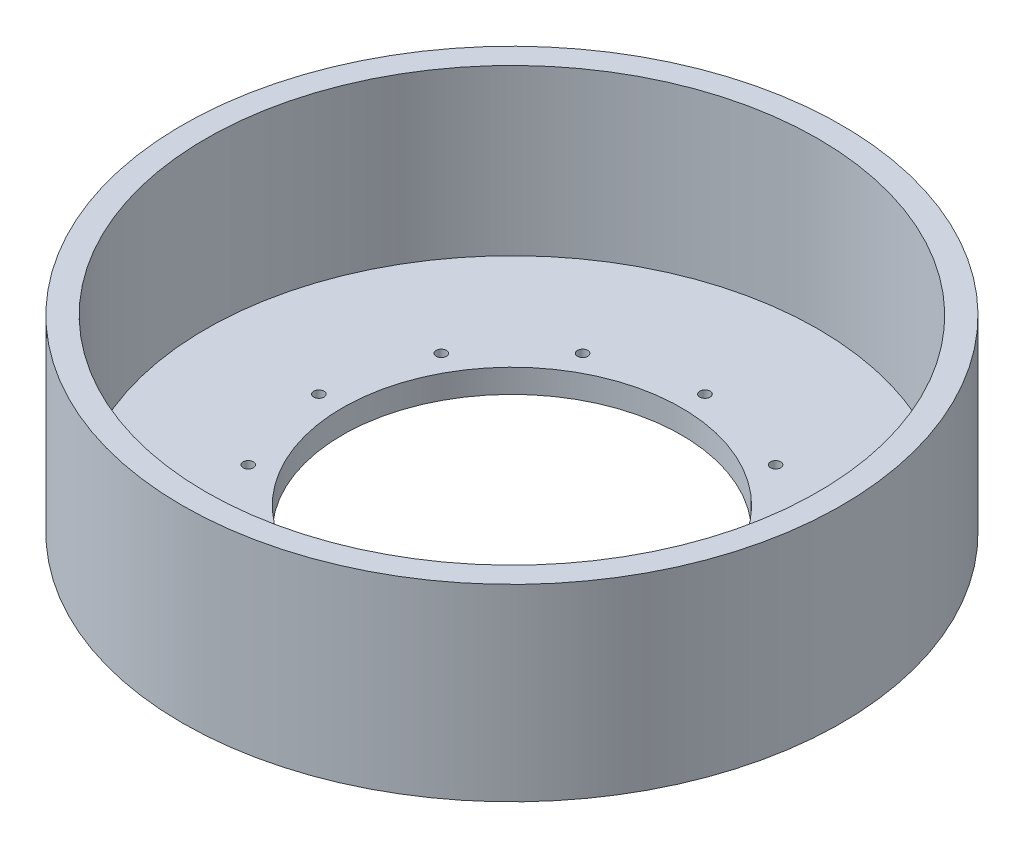
from build123d import *

# Parameters (mm, degrees)
SKETCH1_R           = 88.9
BOSS_EXTRUDE1_DEPTH = 50.8
SKETCH2_R           = 82.55
CUT_EXTRUDE1_DEPTH  = 44.45
SKETCH3_R           = 45.72
SKETCH3_R_2         = 1.397
CUT_EXTRUDE2_DEPTH  = 7.35


with BuildPart() as part:
    # Sketch1 → Boss-Extrude1 (new body)
    with BuildSketch(Plane(origin=(0, 0, 0), x_dir=(1, 0, 0), z_dir=(0, 1, 0))):
        Circle(SKETCH1_R)
    extrude(amount=BOSS_EXTRUDE1_DEPTH)

    # Sketch2 → Cut-Extrude1 (cut)
    with BuildSketch(Plane(origin=(0, 50.8, 0), x_dir=(1, 0, 0), z_dir=(0, 1, 0))):
        Circle(SKETCH2_R)
    extrude(amount=-CUT_EXTRUDE1_DEPTH, mode=Mode.SUBTRACT)

    # Sketch3 → Cut-Extrude2 (cut, through all)
    with BuildSketch(Plane(origin=(0, 6.35, 0), x_dir=(1, 0, 0), z_dir=(0, 1, 0))):
        Circle(SKETCH3_R)
        with Locations((0, 52.07)):
            Circle(SKETCH3_R_2)
        with Locations((26.035, 45.093942775)):
            Circle(SKETCH3_R_2)
        with Locations((45.093942775, 26.035)):
            Circle(SKETCH3_R_2)
        with Locations((52.07, 0)):
            Circle(SKETCH3_R_2)
        with Locations((45.093942775, -26.035)):
            Circle(SKETCH3_R_2)
        with Locations((26.035, -45.093942775)):
            Circle(SKETCH3_R_2)
        with Locations((0, -52.07)):
            Circle(SKETCH3_R_2)
        with Locations((-26.035, -45.093942775)):
            Circle(SKETCH3_R_2)
        with Locations((-45.093942775, -26.035)):
            Circle(SKETCH3_R_2)
        with Locations((-52.07, 0)):
            Circle(SKETCH3_R_2)
        with Locations((-45.093942775, 26.035)):
            Circle(SKETCH3_R_2)
        with Locations((-26.035, 45.093942775)):
            Circle(SKETCH3_R_2)
    extrude(amount=-CUT_EXTRUDE2_DEPTH, mode=Mode.SUBTRACT)


solid = part.part
